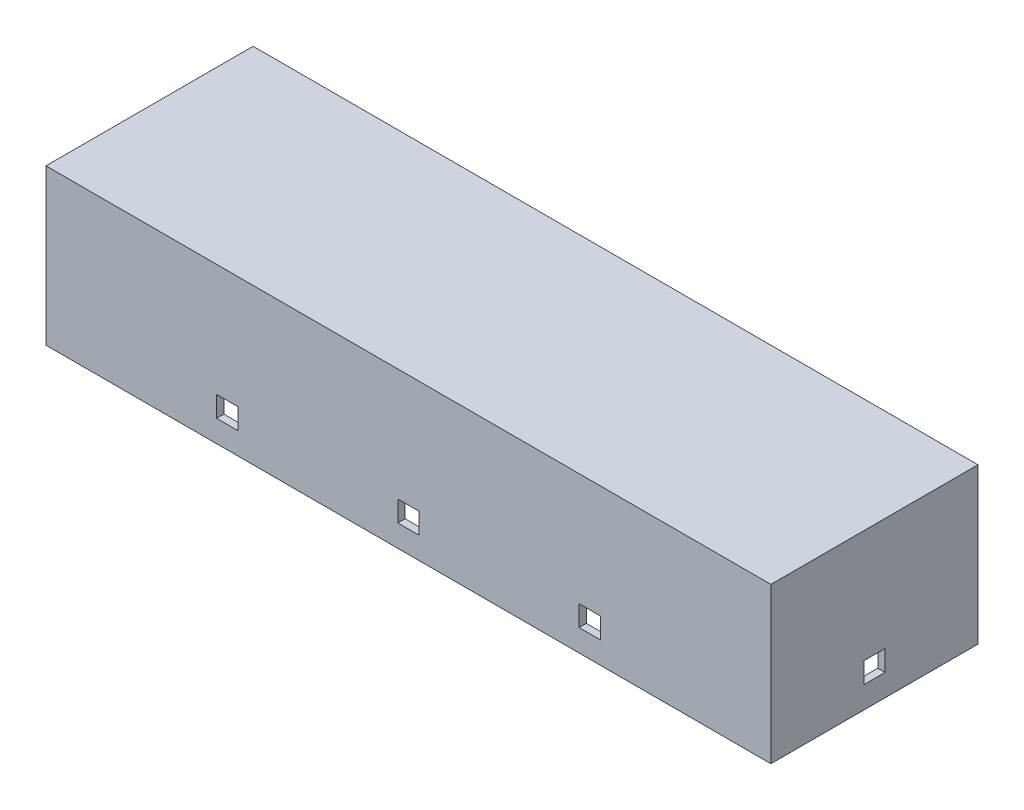
from build123d import *

# Parameters (mm, degrees)
SKETCH1_W           = 140
SKETCH1_H           = 40
BOSS_EXTRUDE1_DEPTH = 30
SKETCH2_W           = 137.2
SKETCH2_H           = 37.2
CUT_EXTRUDE1_DEPTH  = 28.4
SKETCH3_W           = 4.1
SKETCH3_H           = 4
CUT_EXTRUDE2_DEPTH  = 141
SKETCH4_W           = 2.05
SKETCH4_H           = 4
SKETCH4_W_2         = 4.1
CUT_EXTRUDE3_DEPTH  = 41


with BuildPart() as part:
    # Sketch1 → Boss-Extrude1 (new body)
    with BuildSketch(Plane(origin=(0, 0, 0), x_dir=(1, 0, 0), z_dir=(0, 1, 0))):
        Rectangle(SKETCH1_W, SKETCH1_H)
    extrude(amount=BOSS_EXTRUDE1_DEPTH)

    # Sketch2 → Cut-Extrude1 (cut)
    with BuildSketch(Plane.XZ):
        Rectangle(SKETCH2_W, SKETCH2_H)
    extrude(amount=-CUT_EXTRUDE1_DEPTH, mode=Mode.SUBTRACT)

    # Sketch3 → Cut-Extrude2 (cut, through all)
    with BuildSketch(Plane.ZY.offset(70)):
        with Locations((0, 6.25)):
            Rectangle(SKETCH3_W, SKETCH3_H)
    extrude(amount=-CUT_EXTRUDE2_DEPTH, mode=Mode.SUBTRACT)

    # Sketch4 → Cut-Extrude3 (cut, through all)
    with BuildSketch(Plane.XY.offset(20)):
        with Locations((-1.025, 6.25)):
            Rectangle(SKETCH4_W, SKETCH4_H)
        with Locations((-35, 6.25)):
            Rectangle(SKETCH4_W_2, SKETCH4_H)
    cut_extrude3 = extrude(amount=-CUT_EXTRUDE3_DEPTH, mode=Mode.SUBTRACT)

    # Mirror1: Cut-Extrude3 across plane
    add(cut_extrude3.mirror(Plane(origin=(0, 0, 0), x_dir=(0, 0, 1), z_dir=(1, 0, 0))), mode=Mode.SUBTRACT)


solid = part.part
